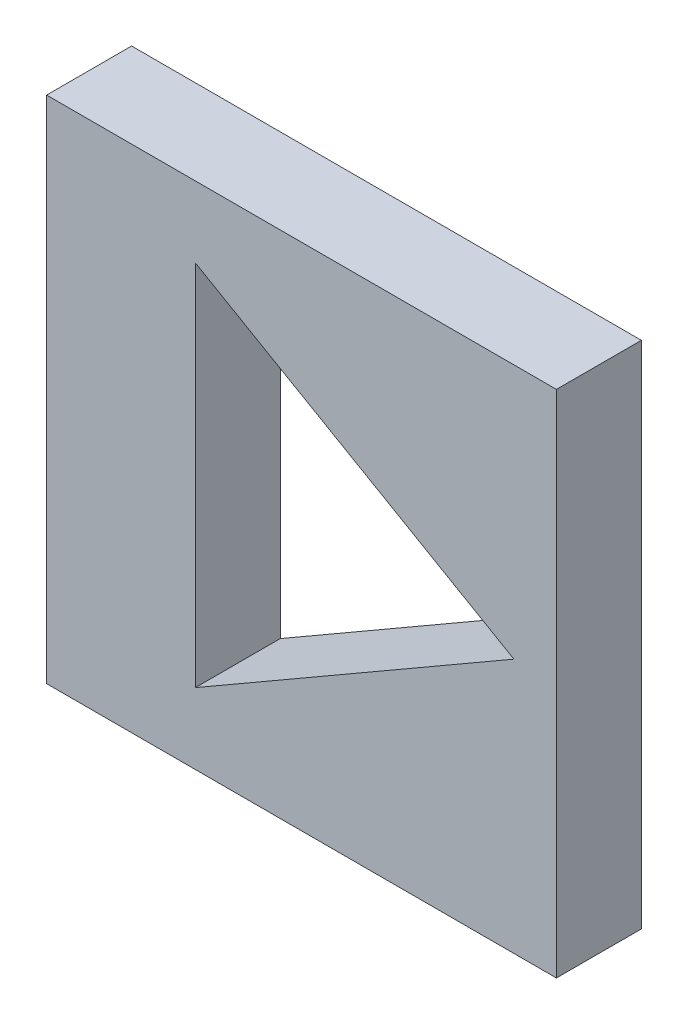
from build123d import *

# Parameters (mm, degrees)
SCHIZZO1_W                   = 60
SCHIZZO1_H                   = 60
ESTRUSIONE_ESTRUSIONE1_DEPTH = 10


with BuildPart() as part:
    # Schizzo1 → Estrusione-Estrusione1 (new body)
    with BuildSketch(Plane.XY):
        Rectangle(SCHIZZO1_W, SCHIZZO1_H)
        Polygon((25, 0), (-12.5, 21.650635095), (-12.5, -21.650635095), align=None, mode=Mode.SUBTRACT)
    extrude(amount=ESTRUSIONE_ESTRUSIONE1_DEPTH)


solid = part.part
